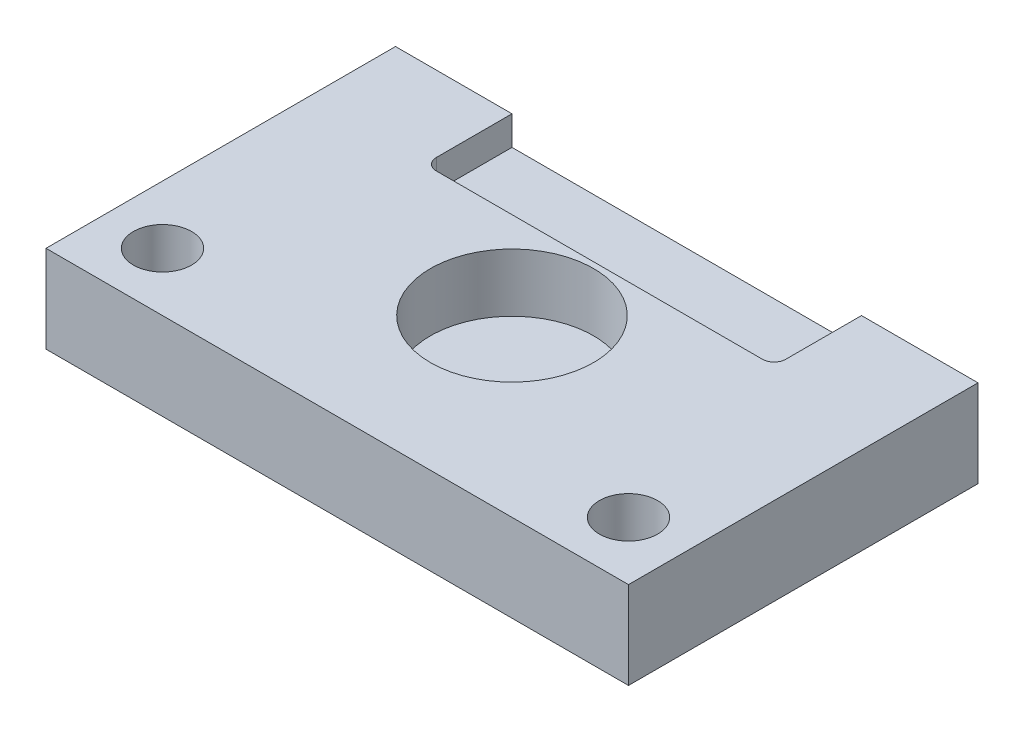
from build123d import *

# Parameters (mm, degrees)
IZIM1_W                     = 100
IZIM1_H                     = 60
Y_KSEKLIK_EKSTR_ZYON1_DEPTH = 15
IZIM2_W                     = 60
IZIM2_H                     = 15
KES_EKSTR_ZYON1_DEPTH       = 5
IZIM3_R                     = 14
KES_EKSTR_ZYON2_DEPTH       = 10
IZIM4_R                     = 5
KES_EKSTR_ZYON3_DEPTH       = 16
RADYUS1_R                   = 2


with BuildPart() as part:
    # Çizim1 → Yükseklik-Ekstrüzyon1 (new body)
    with BuildSketch(Plane(origin=(0, 0, 0), x_dir=(1, 0, 0), z_dir=(0, 1, 0))):
        Rectangle(IZIM1_W, IZIM1_H)
    extrude(amount=Y_KSEKLIK_EKSTR_ZYON1_DEPTH)

    # Çizim2 → Kes-Ekstrüzyon1 (cut)
    with BuildSketch(Plane(origin=(0, 15, 0), x_dir=(1, 0, 0), z_dir=(0, 1, 0))):
        with Locations((0, 22.5)):
            Rectangle(IZIM2_W, IZIM2_H)
    extrude(amount=-KES_EKSTR_ZYON1_DEPTH, mode=Mode.SUBTRACT)

    # Çizim3 → Kes-Ekstrüzyon2 (cut)
    with BuildSketch(Plane(origin=(0, 15, 0), x_dir=(1, 0, 0), z_dir=(0, 1, 0))):
        Circle(IZIM3_R)
    extrude(amount=-KES_EKSTR_ZYON2_DEPTH, mode=Mode.SUBTRACT)

    # Çizim4 → Kes-Ekstrüzyon3 (cut, through all)
    with BuildSketch(Plane(origin=(0, 15, 0), x_dir=(1, 0, 0), z_dir=(0, 1, 0))):
        with Locations((-40, -20)):
            Circle(IZIM4_R)
        with Locations((40, -20)):
            Circle(IZIM4_R)
    extrude(amount=-KES_EKSTR_ZYON3_DEPTH, mode=Mode.SUBTRACT)

    # Radyus1
    radyus1_edges = [part.edges().sort_by_distance(p)[0] for p in [
        (30, 12.5, -15),
        (-30, 12.5, -15),
    ]]
    fillet(radyus1_edges, radius=RADYUS1_R)


solid = part.part
